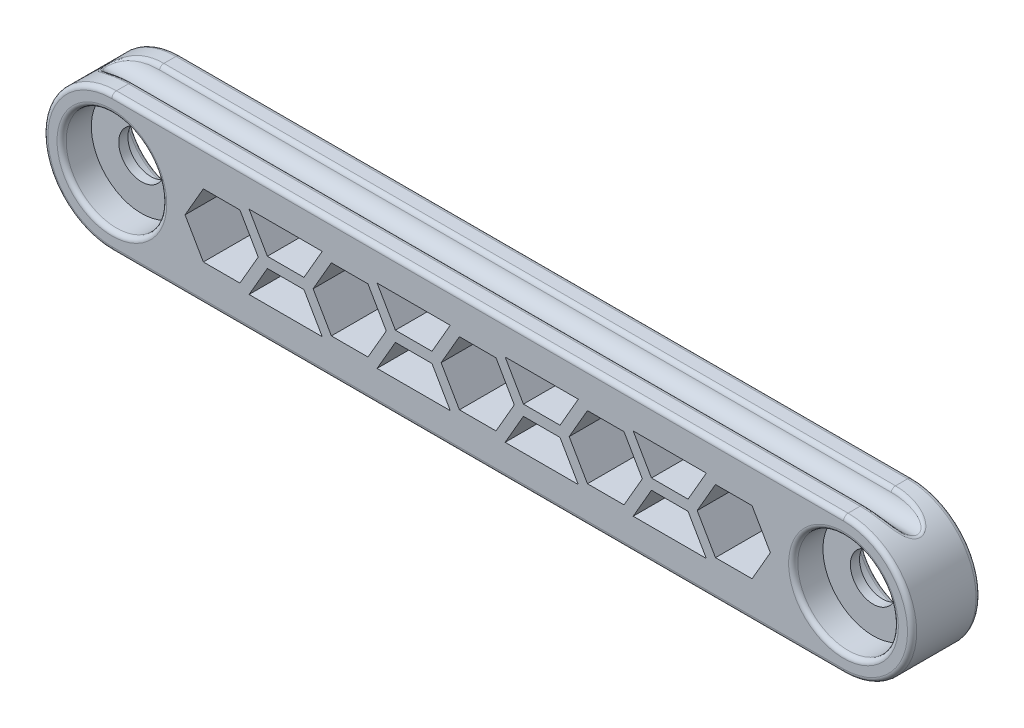
from build123d import *

# Parameters (mm, degrees)
SKETCH1_R               = 5
BOSS_EXTRUDE1_DEPTH     = 1
SKETCH1_3_R             = 11
BOSS_EXTRUDE2_DEPTH     = 7.5
CUT_EXTRUDE1_DEPTH      = 97.468906908
CUT_EXTRUDE1_DEPTH_BACK = 97.468906908
FILLET1_R               = 1
FILLET2_R               = 1
CUT_EXTRUDE3_DEPTH      = 97.468907022
CUT_EXTRUDE4_DEPTH      = 97.468907022
LPATTERN1_COUNT         = 3
LPATTERN1_PITCH         = 28
LPATTERN1_COUNT_DIR2    = 3
LPATTERN1_PITCH_DIR2    = 28
LPATTERN2_COUNT         = 2
LPATTERN2_PITCH         = 28
LPATTERN2_COUNT_DIR2    = 3
LPATTERN2_PITCH_DIR2    = 28


with BuildPart() as part:
    # Sketch1 → Boss-Extrude1 (new, symmetric)
    with BuildSketch(Plane.XY):
        with BuildLine():
            Line((80, 15), (-80, 15))
            ThreePointArc((-80, 15), (-95, 0), (-80, -15))
            Line((-80, -15), (80, -15))
            ThreePointArc((80, -15), (95, 0), (80, 15))
        make_face()
        with Locations((-80, 0)):
            Circle(SKETCH1_R, mode=Mode.SUBTRACT)
        with Locations((80, 0)):
            Circle(SKETCH1_R, mode=Mode.SUBTRACT)
    extrude(amount=BOSS_EXTRUDE1_DEPTH, both=True)

    # Sketch1_3 → Boss-Extrude2 (add, symmetric)
    with BuildSketch(Plane.XY):
        with BuildLine():
            Line((80, 15), (-80, 15))
            ThreePointArc((-80, 15), (-95, 0), (-80, -15))
            Line((-80, -15), (80, -15))
            ThreePointArc((80, -15), (95, 0), (80, 15))
        make_face()
        with Locations((-80, 0)):
            Circle(SKETCH1_3_R, mode=Mode.SUBTRACT)
        with Locations((80, 0)):
            Circle(SKETCH1_3_R, mode=Mode.SUBTRACT)
    extrude(amount=BOSS_EXTRUDE2_DEPTH, both=True)

    # Sketch2 → Cut-Extrude1 (cut, two sides: drawn at the far end of the back side and taken through both)
    with BuildSketch(Plane(origin=(0, 0, 0), x_dir=(0, 0, -1), z_dir=(1, 0, 0)).offset(-CUT_EXTRUDE1_DEPTH_BACK)):
        with BuildLine():
            Line((3, 15), (-3, 15))
            ThreePointArc((-3, 15), (0, 12), (3, 15))
        make_face()
    extrude(amount=CUT_EXTRUDE1_DEPTH + CUT_EXTRUDE1_DEPTH_BACK, mode=Mode.SUBTRACT)

    # Fillet1
    fillet1_edges = [part.edges().sort_by_distance(p)[0] for p in [
        (-89, 12, 0),
        (0, 15, 3),
        (88.9999999, 12.000000075, -0.000670821),
        (0, 15, -3),
    ]]
    fillet(fillet1_edges, radius=FILLET1_R)

    # Fillet2
    fillet2_edges = [part.edges().sort_by_distance(p)[0] for p in [
        (-95, 0, 7.5),
        (0, 15, 7.5),
        (95, 0, 7.5),
        (0, -15, 7.5),
        (-91, 0, 7.5),
        (69, 0, 7.5),
        (95, 0, -7.5),
        (0, 15, -7.5),
        (-95, 0, -7.5),
        (0, -15, -7.5),
        (-91, 0, -7.5),
        (69, 0, -7.5),
    ]]
    fillet(fillet2_edges, radius=FILLET2_R)

    # Sketch5 → Cut-Extrude3 (cut, symmetric)
    with BuildSketch(Plane.XY):
        Polygon((-4, -6.92820323), (4, -6.92820323), (8, 0), (4, 6.92820323), (-4, 6.92820323), (-8, 0), align=None)
    cut_extrude3 = extrude(amount=CUT_EXTRUDE3_DEPTH, both=True, mode=Mode.SUBTRACT)

    # Sketch5_3 → Cut-Extrude4 (cut, symmetric)
    with BuildSketch(Plane.XY):
        Polygon((22, 8.082903769), (6, 8.082903769), (10, 1.154700538), (18, 1.154700538), align=None)
        Polygon((18, -1.154700538), (10, -1.154700538), (6, -8.082903769), (22, -8.082903769), align=None)
    cut_extrude4 = extrude(amount=CUT_EXTRUDE4_DEPTH, both=True, mode=Mode.SUBTRACT)

    # LPattern1: Cut-Extrude3 3 × 3
    with Locations(*[Vector(1, 0, 0) * (i * LPATTERN1_PITCH) + Vector(-1, 0, 0) * (j * LPATTERN1_PITCH_DIR2) for i in range(LPATTERN1_COUNT) for j in range(LPATTERN1_COUNT_DIR2) if (i, j) != (0, 0)]):
        add(cut_extrude3, mode=Mode.SUBTRACT)

    # LPattern2: Cut-Extrude4 2 × 3
    with Locations(*[Vector(1, 0, 0) * (i * LPATTERN2_PITCH) + Vector(-1, 0, 0) * (j * LPATTERN2_PITCH_DIR2) for i in range(LPATTERN2_COUNT) for j in range(LPATTERN2_COUNT_DIR2) if (i, j) != (0, 0)]):
        add(cut_extrude4, mode=Mode.SUBTRACT)


solid = part.part
